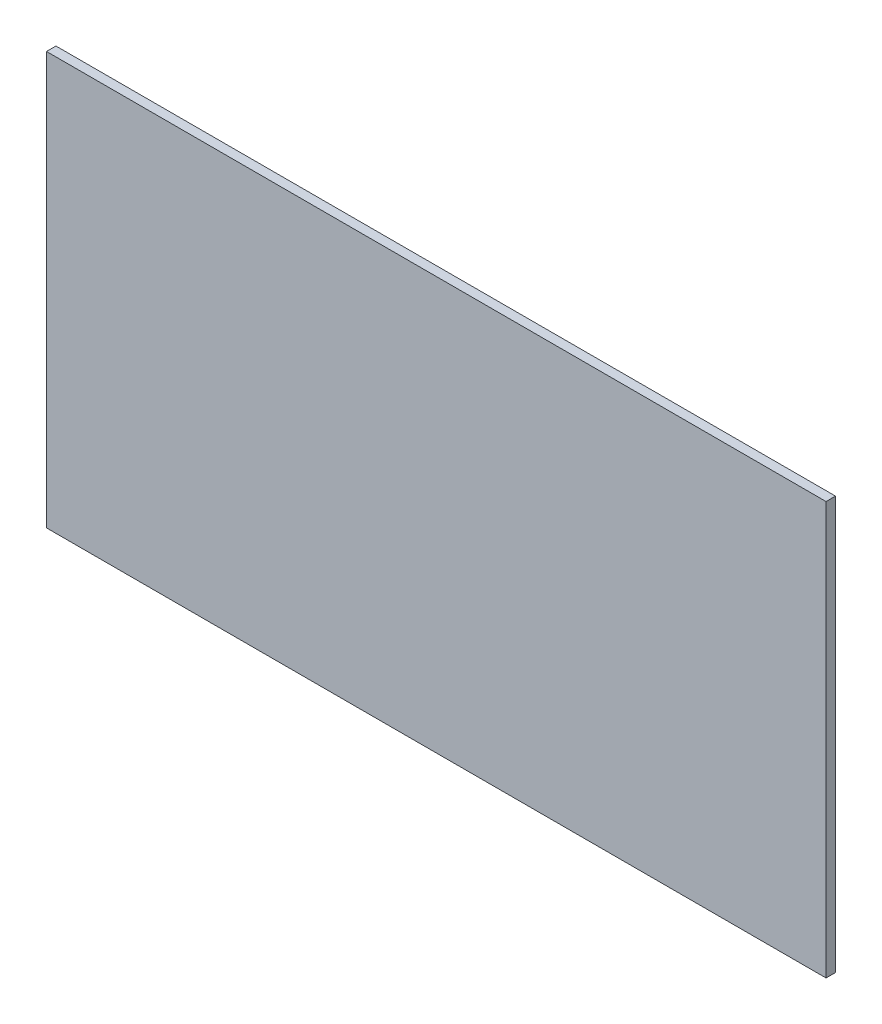
from build123d import *

# Parameters (mm, degrees)
ESBO_O1_W                = 41.28
ESBO_O1_H                = 21.85
RESSALTO_EXTRUS_O1_DEPTH = 0.5


with BuildPart() as part:
    # Esboço1 → Ressalto-extrusão1 (new body)
    with BuildSketch(Plane.XY):
        with Locations((-12.62420765, 3.5)):
            Rectangle(ESBO_O1_W, ESBO_O1_H)
    extrude(amount=RESSALTO_EXTRUS_O1_DEPTH)


solid = part.part
